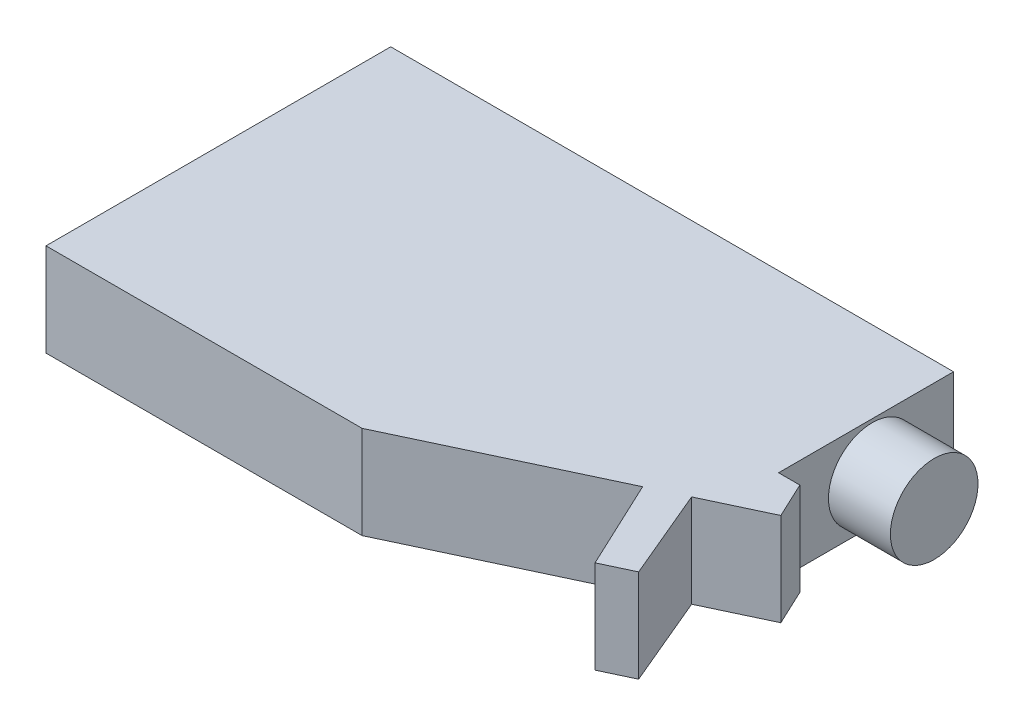
from build123d import *

# Parameters (mm, degrees)
BOSS_EXTRUDE1_DEPTH = 15
SKETCH2_R           = 7.067911596
BOSS_EXTRUDE2_DEPTH = 10


with BuildPart() as part:
    # Sketch1 → Boss-Extrude1 (new body)
    with BuildSketch(Plane(origin=(0, 0, 0), x_dir=(1, 0, 0), z_dir=(0, 1, 0))):
        Polygon((15.245454551, -7.948947663), (46.04976055, 6.529076156), (52.854431745, -7.948947663), (57.639851776, -5.699800249), (51.429912058, 9.057747365), (61.227828764, 13.662768217), (58.508060239, 19.44950976), (55.074851666, 19.44950976), (55.074851666, 47.693685978), (-35.770264484, 47.693685978), (-35.770264484, -7.948947663), align=None)
    extrude(amount=BOSS_EXTRUDE1_DEPTH)

    # Sketch2 → Boss-Extrude2 (add)
    with BuildSketch(Plane(origin=(55.074851666, 0, 0), x_dir=(0, 0, -1), z_dir=(1, 0, 0))):
        with Locations(Location((34.570742976, 7.378151278, 0), (0, 0, 180))):  # turned: the seam where the file's is
            Circle(SKETCH2_R)
    extrude(amount=BOSS_EXTRUDE2_DEPTH)


solid = part.part
